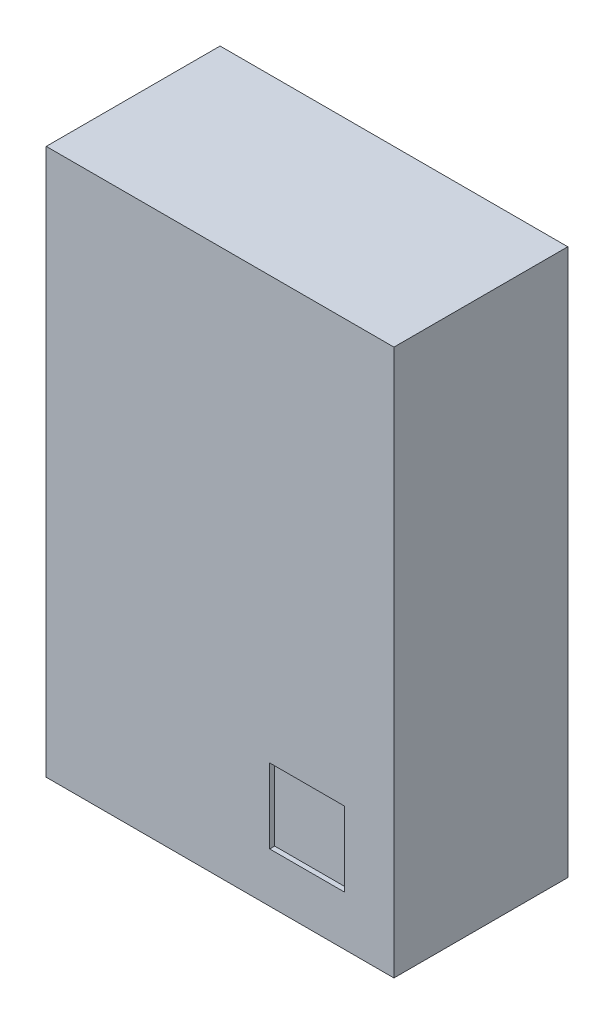
from build123d import *

# Parameters (mm, degrees)
SKETCH1_W           = 0.7
SKETCH1_H           = 1.1
BOSS_EXTRUDE1_DEPTH = 0.35
SKETCH2_W           = 0.2
SKETCH2_H           = 0.2
BOSS_EXTRUDE2_DEPTH = 0.02
SKETCH3_W           = 0.15
SKETCH3_H           = 0.15
CUT_EXTRUDE1_DEPTH  = 0.01


with BuildPart() as part:
    # Sketch1 → Boss-Extrude1 (new body)
    with BuildSketch(Plane.XY):
        Rectangle(SKETCH1_W, SKETCH1_H)
    extrude(amount=BOSS_EXTRUDE1_DEPTH)

    # Sketch2 → Boss-Extrude2 (add)
    with BuildSketch(Plane(origin=(0, 0, 0), x_dir=(-1, 0, 0), z_dir=(0, 0, -1))):
        with Locations((-0.2, 0.4)):
            Rectangle(SKETCH2_W, SKETCH2_H)
        with Locations((-0.2, -0.4)):
            Rectangle(SKETCH2_W, SKETCH2_H)
        with Locations((-0.2, 0)):
            Rectangle(SKETCH2_W, SKETCH2_H)
        with Locations((0.2, -0.4)):
            Rectangle(SKETCH2_W, SKETCH2_H)
        with Locations((0.2, 0)):
            Rectangle(SKETCH2_W, SKETCH2_H)
        with Locations((0.2, 0.4)):
            Rectangle(SKETCH2_W, SKETCH2_H)
    extrude(amount=BOSS_EXTRUDE2_DEPTH)

    # Sketch3 → Cut-Extrude1 (cut)
    with BuildSketch(Plane.XY.offset(0.35)):
        with Locations((0.175, -0.375)):
            Rectangle(SKETCH3_W, SKETCH3_H)
    extrude(amount=-CUT_EXTRUDE1_DEPTH, mode=Mode.SUBTRACT)


solid = part.part
